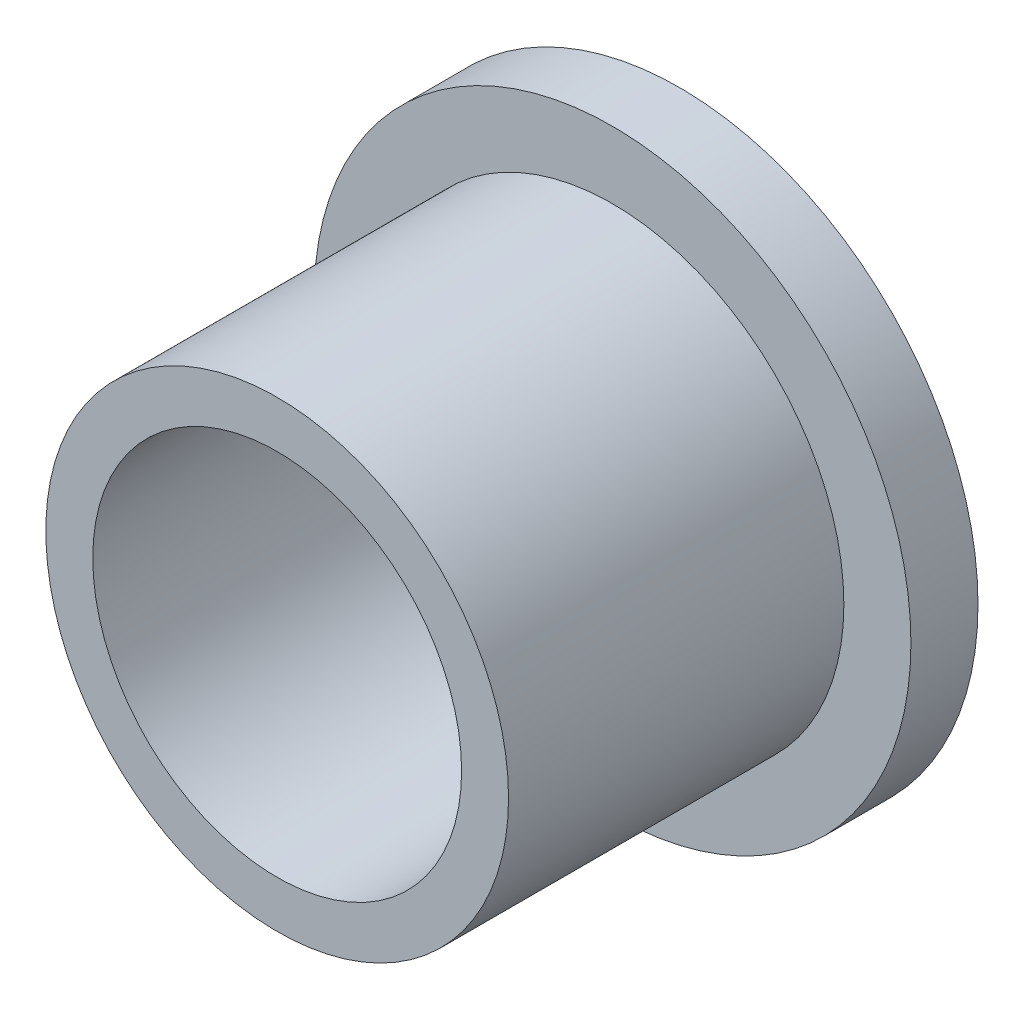
from build123d import *

# Parameters (mm, degrees)
CROQUIS2_R            = 2.75
CORTAR_EXTRUIR1_DEPTH = 10


with BuildPart() as part:
    # Croquis1 one side → Revolución1 (revolve)
    with BuildSketch(Plane(origin=(0, 0, 0), x_dir=(0, 0, -1), z_dir=(1, 0, 0))):
        Polygon((-5.390936577, 3.45), (-10.390936577, 3.45), (-10.390936577, 0), (-4.390936577, 0), (-4.390936577, 4.45), (-5.390936577, 4.45), align=None)
    revolve(axis=Axis((0, 0, 12.072693703), (0, 0, -1)))

    # Croquis2 → Cortar-Extruir1 (cut)
    with BuildSketch(Plane.XY.offset(10.390936577)):
        Circle(CROQUIS2_R)
    extrude(amount=-CORTAR_EXTRUIR1_DEPTH, mode=Mode.SUBTRACT)


solid = part.part
